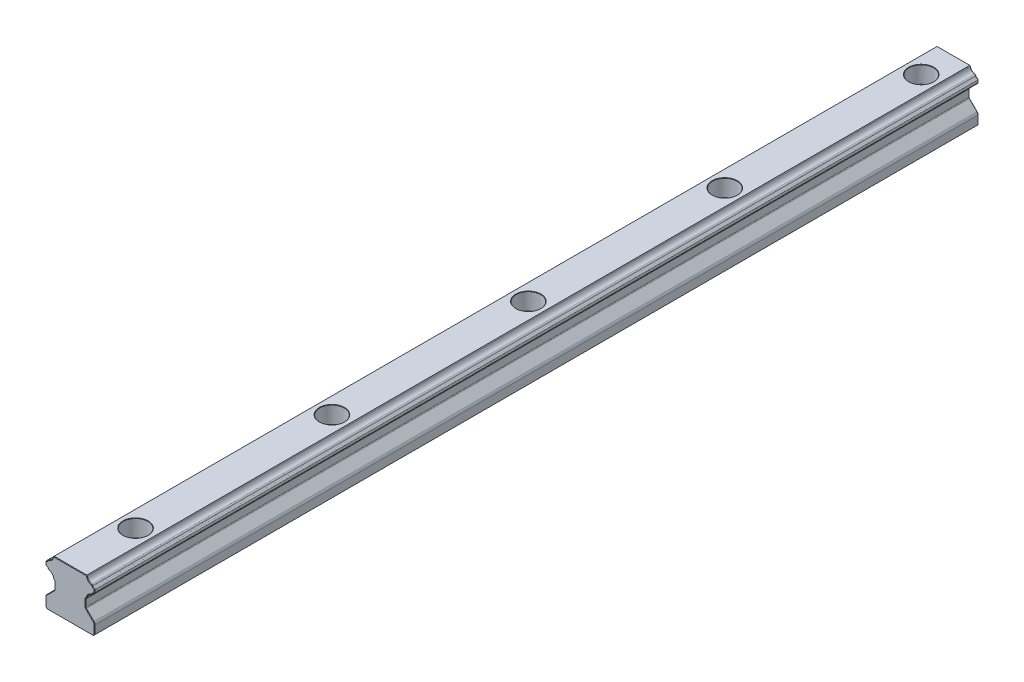
from build123d import *

# Parameters (mm, degrees)
BODY_DEPTH                                 = 270
AESTHETIC_CHAMFER_SIZE                     = 0.15
PRODUCTION_FILLET_R                        = 0.1
MOUNTING_HOLES_PATTERN_COUNT               = 5
MOUNTING_HOLES_PATTERN_PITCH               = 60
PRODUCTION_FILLET_OF_MOUNTING_HOLES_PATT_R = 0.1


with BuildPart() as part:
    # Rail Profile → Body (new body)
    with BuildSketch(Plane.XY):
        with BuildLine():
            Line((-7, 0), (7, 0))
            Line((7, 0), (7.5, 0.5))
            Line((7.5, 0.5), (7.5, 3.085786438))
            ThreePointArc((7.5, 3.085786438), (7.423879533, 3.46846987), (7.207106781, 3.792893219))
            Line((7.207106781, 3.792893219), (4.867157288, 6.132842712))
            ThreePointArc((4.867157288, 6.132842712), (4.780448187, 6.262612052), (4.75, 6.415685425))
            Line((4.75, 6.415685425), (4.75, 8.584314575))
            ThreePointArc((4.75, 8.584314575), (4.780448187, 8.737387948), (4.867157288, 8.867157288))
            Line((4.867157288, 8.867157288), (5.062965362, 9.062965362))
            ThreePointArc((5.062965362, 9.062965362), (5.134996734, 9.161242682), (5.17409812, 9.27664646))
            ThreePointArc((5.17409812, 9.27664646), (5.61862915, 10.13137085), (6.47335354, 10.57590188))
            ThreePointArc((6.47335354, 10.57590188), (6.694124352, 10.694306692), (6.801170165, 10.920803148))
            ThreePointArc((6.801170165, 10.920803148), (6.915305692, 11.154571658), (7.149074202, 11.268707185))
            ThreePointArc((7.149074202, 11.268707185), (7.399691242, 11.400760606), (7.5, 11.665685425))
            Line((7.5, 11.665685425), (7.5, 12.334314575))
            ThreePointArc((7.5, 12.334314575), (7.399691242, 12.599239394), (7.149074202, 12.731292815))
            ThreePointArc((7.149074202, 12.731292815), (6.915305692, 12.845428342), (6.801170165, 13.079196852))
            ThreePointArc((6.801170165, 13.079196852), (6.694124352, 13.305693308), (6.47335354, 13.42409812))
            ThreePointArc((6.47335354, 13.42409812), (5.61862915, 13.86862915), (5.17409812, 14.72335354))
            ThreePointArc((5.17409812, 14.72335354), (5.134996734, 14.838757318), (5.062965362, 14.937034638))
            Line((5.062965362, 14.937034638), (5, 15))
            Line((5, 15), (-5, 15))
            Line((-5, 15), (-5.062965362, 14.937034638))
            ThreePointArc((-5.062965362, 14.937034638), (-5.134996734, 14.838757318), (-5.17409812, 14.72335354))
            ThreePointArc((-5.17409812, 14.72335354), (-5.61862915, 13.86862915), (-6.47335354, 13.42409812))
            ThreePointArc((-6.47335354, 13.42409812), (-6.694124352, 13.305693308), (-6.801170165, 13.079196852))
            ThreePointArc((-6.801170165, 13.079196852), (-6.915305692, 12.845428342), (-7.149074202, 12.731292815))
            ThreePointArc((-7.149074202, 12.731292815), (-7.399691242, 12.599239394), (-7.5, 12.334314575))
            Line((-7.5, 12.334314575), (-7.5, 11.665685425))
            ThreePointArc((-7.5, 11.665685425), (-7.399691242, 11.400760606), (-7.149074202, 11.268707185))
            ThreePointArc((-7.149074202, 11.268707185), (-6.915305692, 11.154571658), (-6.801170165, 10.920803148))
            ThreePointArc((-6.801170165, 10.920803148), (-6.694124352, 10.694306692), (-6.47335354, 10.57590188))
            ThreePointArc((-6.47335354, 10.57590188), (-5.61862915, 10.13137085), (-5.17409812, 9.27664646))
            ThreePointArc((-5.17409812, 9.27664646), (-5.134996734, 9.161242682), (-5.062965362, 9.062965362))
            Line((-5.062965362, 9.062965362), (-4.867157288, 8.867157288))
            ThreePointArc((-4.867157288, 8.867157288), (-4.780448187, 8.737387948), (-4.75, 8.584314575))
            Line((-4.75, 8.584314575), (-4.75, 6.415685425))
            ThreePointArc((-4.75, 6.415685425), (-4.780448187, 6.262612052), (-4.867157288, 6.132842712))
            Line((-4.867157288, 6.132842712), (-7.207106781, 3.792893219))
            ThreePointArc((-7.207106781, 3.792893219), (-7.423879533, 3.46846987), (-7.5, 3.085786438))
            Line((-7.5, 3.085786438), (-7.5, 0.5))
            Line((-7.5, 0.5), (-7, 0))
        make_face()
    extrude(amount=-BODY_DEPTH)

    # Aesthetic Chamfer
    aesthetic_chamfer_edges = [part.edges().sort_by_distance(p)[0] for p in [
        (7.423879533, 3.46846987, -270),
        (-5.134996734, 9.161242682, -270),
        (-4.965061325, 8.965061325, -270),
        (-4.780448187, 8.737387948, -270),
        (-4.75, 7.5, -270),
        (-4.780448187, 6.262612052, -270),
        (-6.037132034, 4.962867966, -270),
        (-7.423879533, 3.46846987, -270),
        (-7.5, 1.792893219, -270),
        (-7.25, 0.25, -270),
        (0, 0, -270),
        (6.037132034, 4.962867966, -270),
        (4.780448187, 6.262612052, -270),
        (4.75, 7.5, -270),
        (4.780448187, 8.737387948, -270),
        (4.965061325, 8.965061325, -270),
        (5.134996734, 9.161242682, -270),
        (5.61862915, 10.13137085, -270),
        (6.694124352, 10.694306692, -270),
        (0, 0, 0),
        (-7.25, 0.25, 0),
        (-7.5, 1.792893219, 0),
        (-7.423879533, 3.46846987, 0),
        (-6.037132034, 4.962867966, 0),
        (-4.780448187, 6.262612052, 0),
        (6.915305692, 11.154571658, -270),
        (-4.75, 7.5, 0),
        (-4.780448187, 8.737387948, 0),
        (-4.965061325, 8.965061325, 0),
        (-5.134996734, 9.161242682, 0),
        (-5.61862915, 10.13137085, 0),
        (-6.694124352, 10.694306692, 0),
        (-6.915305692, 11.154571658, 0),
        (7.25, 0.25, -270),
        (7.399691242, 11.400760606, -270),
        (-7.399691242, 11.400760606, 0),
        (-7.5, 12, 0),
        (-7.399691242, 12.599239394, 0),
        (-6.915305692, 12.845428342, 0),
        (-6.694124352, 13.305693308, 0),
        (-5.61862915, 13.86862915, 0),
        (-5.134996734, 14.838757318, 0),
        (-5.031482681, 14.968517319, 0),
        (7.5, 12, -270),
        (0, 15, 0),
        (5.031482681, 14.968517319, 0),
        (5.134996734, 14.838757318, 0),
        (5.61862915, 13.86862915, 0),
        (6.694124352, 13.305693308, 0),
        (6.915305692, 12.845428342, 0),
        (7.399691242, 12.599239394, 0),
        (7.399691242, 12.599239394, -270),
        (7.5, 12, 0),
        (7.399691242, 11.400760606, 0),
        (6.915305692, 11.154571658, 0),
        (6.694124352, 10.694306692, 0),
        (5.61862915, 10.13137085, 0),
        (5.134996734, 9.161242682, 0),
        (4.965061325, 8.965061325, 0),
        (4.780448187, 8.737387948, 0),
        (6.915305692, 12.845428342, -270),
        (4.75, 7.5, 0),
        (4.780448187, 6.262612052, 0),
        (6.037132034, 4.962867966, 0),
        (7.423879533, 3.46846987, 0),
        (7.5, 1.792893219, 0),
        (7.25, 0.25, 0),
        (6.694124352, 13.305693308, -270),
        (5.61862915, 13.86862915, -270),
        (5.134996734, 14.838757318, -270),
        (5.031482681, 14.968517319, -270),
        (0, 15, -270),
        (-5.031482681, 14.968517319, -270),
        (7.5, 1.792893219, -270),
        (-5.134996734, 14.838757318, -270),
        (-5.61862915, 13.86862915, -270),
        (-6.694124352, 13.305693308, -270),
        (-6.915305692, 12.845428342, -270),
        (-7.399691242, 12.599239394, -270),
        (-7.5, 12, -270),
        (-7.399691242, 11.400760606, -270),
        (-6.915305692, 11.154571658, -270),
        (-6.694124352, 10.694306692, -270),
        (-5.61862915, 10.13137085, -270),
    ]]
    chamfer(aesthetic_chamfer_edges, length=AESTHETIC_CHAMFER_SIZE)

    # Sketch1 → Mounting Hole (revolve, cut)
    with BuildSketch(Plane(origin=(0, 15, -20), x_dir=(0, 0, 1), z_dir=(1, 0, 0))):
        Polygon((0, 0), (0, 15), (2.35, 15), (2.25, 14.9), (2.25, 5.4), (2.35, 5.3), (3.75, 5.3), (3.75, 0.1), (3.85, 0), align=None)
    mounting_hole = revolve(axis=Axis((0, 21.35, -20), (0, -1, 0)), mode=Mode.SUBTRACT)

    # Production Fillet
    production_fillet_edges = [part.edges().sort_by_distance(p)[0] for p in [
        (0, 9.7, -23.75),
    ]]
    fillet(production_fillet_edges, radius=PRODUCTION_FILLET_R)

    # Mounting Holes Pattern: Mounting Hole ×5
    with Locations(*[(0, 0, -i * MOUNTING_HOLES_PATTERN_PITCH) for i in range(1, MOUNTING_HOLES_PATTERN_COUNT)]):
        add(mounting_hole, mode=Mode.SUBTRACT)

    # Production Fillet of Mounting Holes Patt
    production_fillet_of_mounting_holes_patt_edges = [part.edges().sort_by_distance(p)[0] for p in [
        (0, 9.7, -83.75),
        (0, 9.7, -143.75),
        (0, 9.7, -203.75),
        (0, 9.7, -263.75),
    ]]
    fillet(production_fillet_of_mounting_holes_patt_edges, radius=PRODUCTION_FILLET_OF_MOUNTING_HOLES_PATT_R)


solid = part.part
